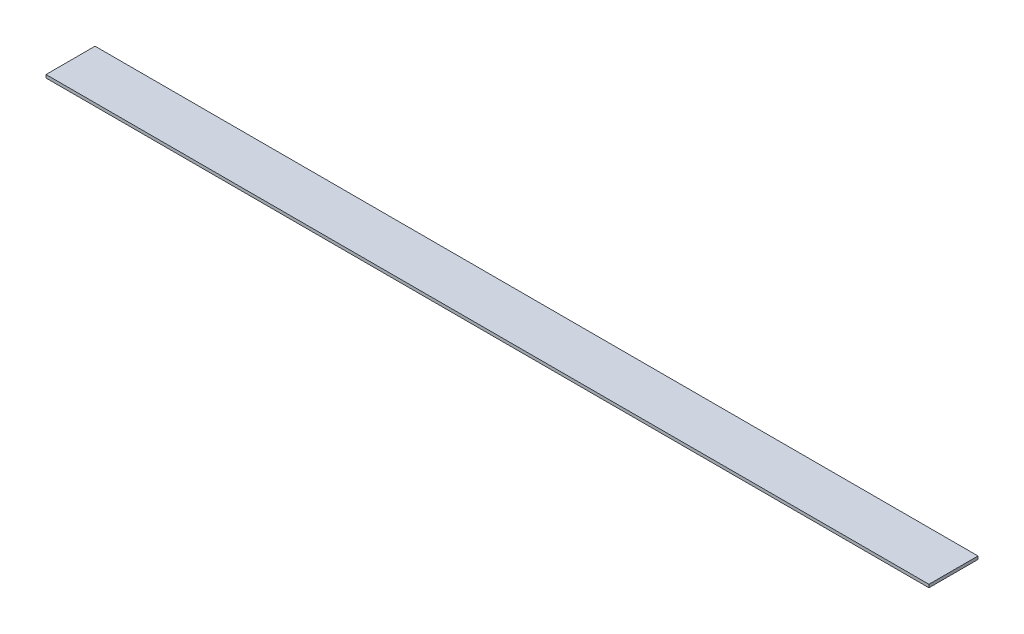
from build123d import *

# Parameters (mm, degrees)
SKETCH1_W           = 914.4
SKETCH1_H           = 50.8
BOSS_EXTRUDE1_DEPTH = 3.175


with BuildPart() as part:
    # Sketch1 → Boss-Extrude1 (new body)
    with BuildSketch(Plane(origin=(0, 0, 0), x_dir=(1, 0, 0), z_dir=(0, 1, 0))):
        Rectangle(SKETCH1_W, SKETCH1_H)
    extrude(amount=BOSS_EXTRUDE1_DEPTH)


solid = part.part
